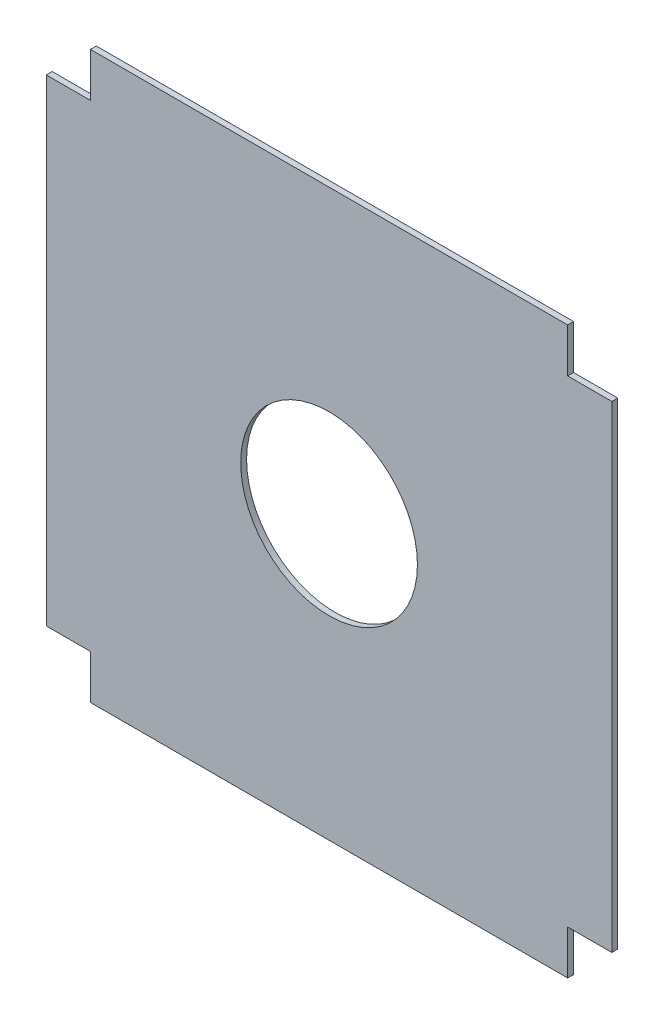
from build123d import *

# Parameters (mm, degrees)
BOSS_EXTRUDE1_DEPTH = 1
SKETCH2_R           = 15
CUT_EXTRUDE1_DEPTH  = 10


with BuildPart() as part:
    # Sketch1 → Boss-Extrude1 (new body)
    with BuildSketch(Plane.XY):
        Polygon((-48, 40.5), (-40.5, 40.5), (-40.5, 48), (40.5, 48), (40.5, 40.5), (48, 40.5), (48, -40.5), (40.5, -40.5), (40.5, -48), (-40.5, -48), (-40.5, -40.5), (-48, -40.5), align=None)
    extrude(amount=BOSS_EXTRUDE1_DEPTH)

    # Sketch2 → Cut-Extrude1 (cut)
    with BuildSketch(Plane.XY.offset(1)):
        Circle(SKETCH2_R)
    extrude(amount=-CUT_EXTRUDE1_DEPTH, mode=Mode.SUBTRACT)


solid = part.part
